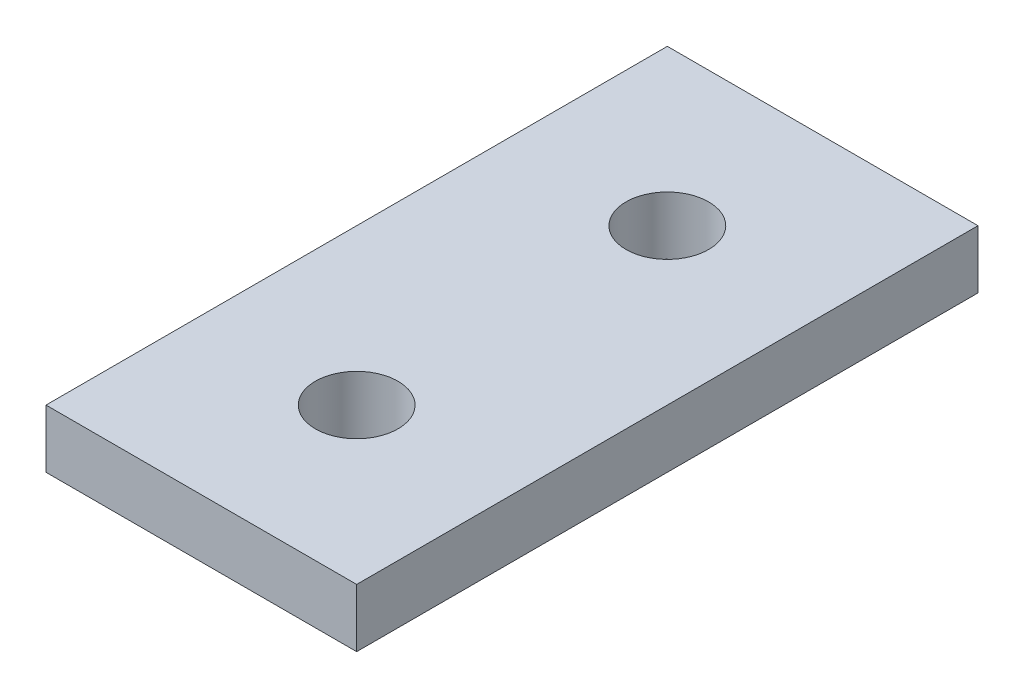
from build123d import *

# Parameters (mm, degrees)
SKETCH1_W           = 25.4
SKETCH1_H           = 50.8
SKETCH1_R           = 3.3782
BOSS_EXTRUDE1_DEPTH = 4.7625


with BuildPart() as part:
    # Sketch1 → Boss-Extrude1 (new body)
    with BuildSketch(Plane(origin=(0, 0, 0), x_dir=(1, 0, 0), z_dir=(0, 1, 0))):
        with Locations((12.7, 25.4)):
            Rectangle(SKETCH1_W, SKETCH1_H)
        with Locations((12.7, 38.1)):
            Circle(SKETCH1_R, mode=Mode.SUBTRACT)
        with Locations((12.7, 12.7)):
            Circle(SKETCH1_R, mode=Mode.SUBTRACT)
    extrude(amount=BOSS_EXTRUDE1_DEPTH)


solid = part.part
